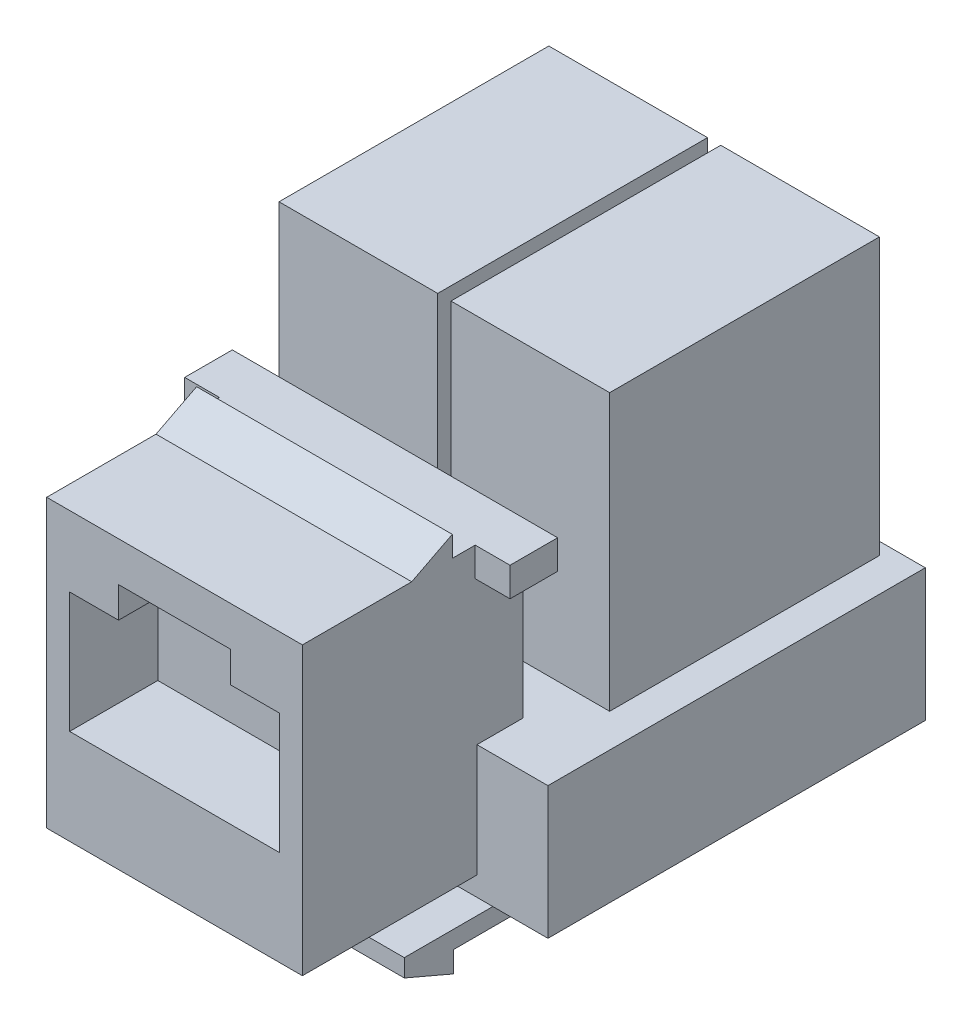
from build123d import *

# Parameters (mm, degrees)
ESBO_O1_W                = 14.5
ESBO_O1_H                = 16.25
RESSALTO_EXTRUS_O1_DEPTH = 12.5
RESSALTO_EXTRUS_O2_DEPTH = 14.5
ESBO_O3_W                = 18.45
ESBO_O3_H                = 2.7
RESSALTO_EXTRUS_O3_DEPTH = 1.65
CORTE_EXTRUS_O1_DEPTH    = 5
RESSALTO_EXTRUS_O4_START = -9.9
ESBO_O5_W                = 22.55
ESBO_O5_H                = 7.5
RESSALTO_EXTRUS_O4_DEPTH = 21.4
ESBO_O6_W                = 9
ESBO_O6_H                = 15.3
RESSALTO_EXTRUS_O5_DEPTH = 15.65
RESSALTO_EXTRUS_O6_DEPTH = 14.5
RESSALTO_EXTRUS_O7_DEPTH = 14.5


with BuildPart() as part:
    # Esboço1 → Ressalto-extrusão1 (new body)
    with BuildSketch(Plane.XY):
        Rectangle(ESBO_O1_W, ESBO_O1_H)
    extrude(amount=RESSALTO_EXTRUS_O1_DEPTH)

    # Esboço2 → Ressalto-extrusão2 (add)
    with BuildSketch(Plane.ZY.offset(7.25)):
        Polygon((6.3, 8.125), (4, 9.305), (4, 8.125), align=None)
    extrude(amount=-RESSALTO_EXTRUS_O2_DEPTH)

    # Esboço3 → Ressalto-extrusão3 (add)
    with BuildSketch(Plane(origin=(0, 8.125, 0), x_dir=(1, 0, 0), z_dir=(0, 1, 0))):
        with Locations((0, -1.35)):
            Rectangle(ESBO_O3_W, ESBO_O3_H)
    extrude(amount=-RESSALTO_EXTRUS_O3_DEPTH)

    # Esboço4 → Corte-extrusão1 (cut)
    with BuildSketch(Plane.XY.offset(12.5)):
        Polygon((-5.95, 4.125), (-3.175, 4.125), (-3.175, 5.875), (3.175, 5.875), (3.175, 4.125), (5.95, 4.125), (5.95, -2.725), (-5.95, -2.725), align=None)
    extrude(amount=-CORTE_EXTRUS_O1_DEPTH, mode=Mode.SUBTRACT)

    # Esboço5 → Ressalto-extrusão4 (add)
    with BuildSketch(Plane.XY.offset(12.5).offset(RESSALTO_EXTRUS_O4_START)):
        with Locations((0, -5.475)):
            Rectangle(ESBO_O5_W, ESBO_O5_H)
    extrude(amount=-RESSALTO_EXTRUS_O4_DEPTH)

    # Esboço6 → Ressalto-extrusão5 (add)
    with BuildSketch(Plane(origin=(0, -1.725, 0), x_dir=(1, 0, 0), z_dir=(0, 1, 0))):
        with Locations((-4.875, 10.45)):
            Rectangle(ESBO_O6_W, ESBO_O6_H)
        with Locations((4.875, 10.45)):
            Rectangle(ESBO_O6_W, ESBO_O6_H)
    extrude(amount=RESSALTO_EXTRUS_O5_DEPTH)

    # Esboço7 → Ressalto-extrusão6 (add)
    with BuildSketch(Plane.ZY.offset(7.25)):
        Polygon((-5.28, -9.225), (-5.28, -11.125), (6.72, -11.125), (6.72, -10.125), (-0.78, -10.125), (-0.78, -9.225), align=None)
    extrude(amount=-RESSALTO_EXTRUS_O6_DEPTH)

    # Esboço8 → Ressalto-extrusão7 (add)
    with BuildSketch(Plane.ZY.offset(7.25)):
        Polygon((6.72, -11.125), (3.92, -12.325), (3.92, -11.125), align=None)
    extrude(amount=-RESSALTO_EXTRUS_O7_DEPTH)


solid = part.part
